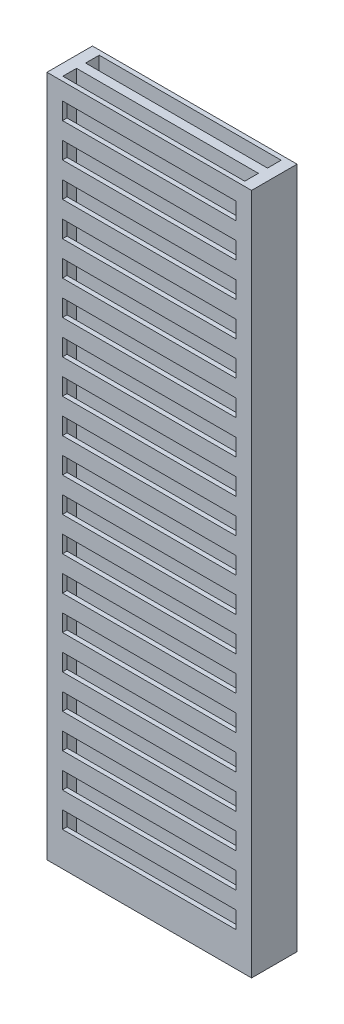
from build123d import *

# Parameters (mm, degrees)
SKETCH1_W                = 9
SKETCH1_H                = 2
BOSS_EXTRUDE1_DEPTH      = 15
CUT_EXTRUDE1_START       = -31
SKETCH2_W                = 8
SKETCH2_H                = 0.6
CUT_EXTRUDE1_DEPTH       = 32
SKETCH3_W                = 7.634272068
SKETCH3_H                = 0.75
CUT_EXTRUDE2_DEPTH       = 0.2
LPATTERN1_COUNT          = 19
LPATTERN1_PITCH          = 1.5
MIRROR2_COPY_1_SKETCH_W  = 7.634272068
MIRROR2_COPY_1_SKETCH_H  = 0.75
MIRROR2_COPY_1_DEPTH     = 0.2
MIRROR2_COPY_2_SKETCH_W  = 7.634272068
MIRROR2_COPY_2_SKETCH_H  = 0.75
MIRROR2_COPY_2_DEPTH     = 0.2
MIRROR2_COPY_3_SKETCH_W  = 7.634272068
MIRROR2_COPY_3_SKETCH_H  = 0.75
MIRROR2_COPY_3_DEPTH     = 0.2
MIRROR2_COPY_4_SKETCH_W  = 7.634272068
MIRROR2_COPY_4_SKETCH_H  = 0.75
MIRROR2_COPY_4_DEPTH     = 0.2
MIRROR2_COPY_5_SKETCH_W  = 7.634272068
MIRROR2_COPY_5_SKETCH_H  = 0.75
MIRROR2_COPY_5_DEPTH     = 0.2
MIRROR2_COPY_6_SKETCH_W  = 7.634272068
MIRROR2_COPY_6_SKETCH_H  = 0.75
MIRROR2_COPY_6_DEPTH     = 0.2
MIRROR2_COPY_7_SKETCH_W  = 7.634272068
MIRROR2_COPY_7_SKETCH_H  = 0.75
MIRROR2_COPY_7_DEPTH     = 0.2
MIRROR2_COPY_8_SKETCH_W  = 7.634272068
MIRROR2_COPY_8_SKETCH_H  = 0.75
MIRROR2_COPY_8_DEPTH     = 0.2
MIRROR2_COPY_9_SKETCH_W  = 7.634272068
MIRROR2_COPY_9_SKETCH_H  = 0.75
MIRROR2_COPY_9_DEPTH     = 0.2
MIRROR2_COPY_10_SKETCH_W = 7.634272068
MIRROR2_COPY_10_SKETCH_H = 0.75
MIRROR2_COPY_10_DEPTH    = 0.2
MIRROR2_COPY_11_SKETCH_W = 7.634272068
MIRROR2_COPY_11_SKETCH_H = 0.75
MIRROR2_COPY_11_DEPTH    = 0.2
MIRROR2_COPY_12_SKETCH_W = 7.634272068
MIRROR2_COPY_12_SKETCH_H = 0.75
MIRROR2_COPY_12_DEPTH    = 0.2
MIRROR2_COPY_13_SKETCH_W = 7.634272068
MIRROR2_COPY_13_SKETCH_H = 0.75
MIRROR2_COPY_13_DEPTH    = 0.2
MIRROR2_COPY_14_SKETCH_W = 7.634272068
MIRROR2_COPY_14_SKETCH_H = 0.75
MIRROR2_COPY_14_DEPTH    = 0.2
MIRROR2_COPY_15_SKETCH_W = 7.634272068
MIRROR2_COPY_15_SKETCH_H = 0.75
MIRROR2_COPY_15_DEPTH    = 0.2
MIRROR2_COPY_16_SKETCH_W = 7.634272068
MIRROR2_COPY_16_SKETCH_H = 0.75
MIRROR2_COPY_16_DEPTH    = 0.2
MIRROR2_COPY_17_SKETCH_W = 7.634272068
MIRROR2_COPY_17_SKETCH_H = 0.75
MIRROR2_COPY_17_DEPTH    = 0.2
MIRROR2_COPY_18_SKETCH_W = 7.634272068
MIRROR2_COPY_18_SKETCH_H = 0.75
MIRROR2_COPY_18_DEPTH    = 0.2


with BuildPart() as part:
    # Sketch1 → Boss-Extrude1 (new body, symmetric)
    with BuildSketch(Plane(origin=(0, 0, 0), x_dir=(1, 0, 0), z_dir=(0, 1, 0))):
        Rectangle(SKETCH1_W, SKETCH1_H)
    extrude(amount=BOSS_EXTRUDE1_DEPTH, both=True)

    # Sketch2 → Cut-Extrude1 (cut)
    with BuildSketch(Plane(origin=(0, 15, 0), x_dir=(1, 0, 0), z_dir=(0, 1, 0)).offset(CUT_EXTRUDE1_START)):
        with Locations((0, 0.5)):
            Rectangle(SKETCH2_W, SKETCH2_H)
    cut_extrude1 = extrude(amount=CUT_EXTRUDE1_DEPTH, mode=Mode.SUBTRACT)

    # Mirror1: Cut-Extrude1 across plane
    add(cut_extrude1.mirror(Plane.XY), mode=Mode.SUBTRACT)

    # Sketch3 → Cut-Extrude2 (cut)
    with BuildSketch(Plane.XY.offset(1)):
        with Locations((0, 13.875)):
            Rectangle(SKETCH3_W, SKETCH3_H)
    cut_extrude2 = extrude(amount=-CUT_EXTRUDE2_DEPTH, mode=Mode.SUBTRACT)

    # LPattern1: Cut-Extrude2 ×19
    with Locations(*[(0, -i * LPATTERN1_PITCH, 0) for i in range(1, LPATTERN1_COUNT)]):
        add(cut_extrude2, mode=Mode.SUBTRACT)

    # Mirror2: Cut-Extrude2 across plane
    add(cut_extrude2.mirror(Plane.XY), mode=Mode.SUBTRACT)

    # Mirror2 copy 1 sketch → Mirror2 copy 1 (cut)
    with BuildSketch(Plane(origin=(0, -1.5, -1), x_dir=(1, 0, 0), z_dir=(0, 0, -1))):
        with Locations((0, -13.875)):
            Rectangle(MIRROR2_COPY_1_SKETCH_W, MIRROR2_COPY_1_SKETCH_H)
    extrude(amount=-MIRROR2_COPY_1_DEPTH, mode=Mode.SUBTRACT)

    # Mirror2 copy 2 sketch → Mirror2 copy 2 (cut)
    with BuildSketch(Plane(origin=(0, -3, -1), x_dir=(1, 0, 0), z_dir=(0, 0, -1))):
        with Locations((0, -13.875)):
            Rectangle(MIRROR2_COPY_2_SKETCH_W, MIRROR2_COPY_2_SKETCH_H)
    extrude(amount=-MIRROR2_COPY_2_DEPTH, mode=Mode.SUBTRACT)

    # Mirror2 copy 3 sketch → Mirror2 copy 3 (cut)
    with BuildSketch(Plane(origin=(0, -4.5, -1), x_dir=(1, 0, 0), z_dir=(0, 0, -1))):
        with Locations((0, -13.875)):
            Rectangle(MIRROR2_COPY_3_SKETCH_W, MIRROR2_COPY_3_SKETCH_H)
    extrude(amount=-MIRROR2_COPY_3_DEPTH, mode=Mode.SUBTRACT)

    # Mirror2 copy 4 sketch → Mirror2 copy 4 (cut)
    with BuildSketch(Plane(origin=(0, -6, -1), x_dir=(1, 0, 0), z_dir=(0, 0, -1))):
        with Locations((0, -13.875)):
            Rectangle(MIRROR2_COPY_4_SKETCH_W, MIRROR2_COPY_4_SKETCH_H)
    extrude(amount=-MIRROR2_COPY_4_DEPTH, mode=Mode.SUBTRACT)

    # Mirror2 copy 5 sketch → Mirror2 copy 5 (cut)
    with BuildSketch(Plane(origin=(0, -7.5, -1), x_dir=(1, 0, 0), z_dir=(0, 0, -1))):
        with Locations((0, -13.875)):
            Rectangle(MIRROR2_COPY_5_SKETCH_W, MIRROR2_COPY_5_SKETCH_H)
    extrude(amount=-MIRROR2_COPY_5_DEPTH, mode=Mode.SUBTRACT)

    # Mirror2 copy 6 sketch → Mirror2 copy 6 (cut)
    with BuildSketch(Plane(origin=(0, -9, -1), x_dir=(1, 0, 0), z_dir=(0, 0, -1))):
        with Locations((0, -13.875)):
            Rectangle(MIRROR2_COPY_6_SKETCH_W, MIRROR2_COPY_6_SKETCH_H)
    extrude(amount=-MIRROR2_COPY_6_DEPTH, mode=Mode.SUBTRACT)

    # Mirror2 copy 7 sketch → Mirror2 copy 7 (cut)
    with BuildSketch(Plane(origin=(0, -10.5, -1), x_dir=(1, 0, 0), z_dir=(0, 0, -1))):
        with Locations((0, -13.875)):
            Rectangle(MIRROR2_COPY_7_SKETCH_W, MIRROR2_COPY_7_SKETCH_H)
    extrude(amount=-MIRROR2_COPY_7_DEPTH, mode=Mode.SUBTRACT)

    # Mirror2 copy 8 sketch → Mirror2 copy 8 (cut)
    with BuildSketch(Plane(origin=(0, -12, -1), x_dir=(1, 0, 0), z_dir=(0, 0, -1))):
        with Locations((0, -13.875)):
            Rectangle(MIRROR2_COPY_8_SKETCH_W, MIRROR2_COPY_8_SKETCH_H)
    extrude(amount=-MIRROR2_COPY_8_DEPTH, mode=Mode.SUBTRACT)

    # Mirror2 copy 9 sketch → Mirror2 copy 9 (cut)
    with BuildSketch(Plane(origin=(0, -13.5, -1), x_dir=(1, 0, 0), z_dir=(0, 0, -1))):
        with Locations((0, -13.875)):
            Rectangle(MIRROR2_COPY_9_SKETCH_W, MIRROR2_COPY_9_SKETCH_H)
    extrude(amount=-MIRROR2_COPY_9_DEPTH, mode=Mode.SUBTRACT)

    # Mirror2 copy 10 sketch → Mirror2 copy 10 (cut)
    with BuildSketch(Plane(origin=(0, -15, -1), x_dir=(1, 0, 0), z_dir=(0, 0, -1))):
        with Locations((0, -13.875)):
            Rectangle(MIRROR2_COPY_10_SKETCH_W, MIRROR2_COPY_10_SKETCH_H)
    extrude(amount=-MIRROR2_COPY_10_DEPTH, mode=Mode.SUBTRACT)

    # Mirror2 copy 11 sketch → Mirror2 copy 11 (cut)
    with BuildSketch(Plane(origin=(0, -16.5, -1), x_dir=(1, 0, 0), z_dir=(0, 0, -1))):
        with Locations((0, -13.875)):
            Rectangle(MIRROR2_COPY_11_SKETCH_W, MIRROR2_COPY_11_SKETCH_H)
    extrude(amount=-MIRROR2_COPY_11_DEPTH, mode=Mode.SUBTRACT)

    # Mirror2 copy 12 sketch → Mirror2 copy 12 (cut)
    with BuildSketch(Plane(origin=(0, -18, -1), x_dir=(1, 0, 0), z_dir=(0, 0, -1))):
        with Locations((0, -13.875)):
            Rectangle(MIRROR2_COPY_12_SKETCH_W, MIRROR2_COPY_12_SKETCH_H)
    extrude(amount=-MIRROR2_COPY_12_DEPTH, mode=Mode.SUBTRACT)

    # Mirror2 copy 13 sketch → Mirror2 copy 13 (cut)
    with BuildSketch(Plane(origin=(0, -19.5, -1), x_dir=(1, 0, 0), z_dir=(0, 0, -1))):
        with Locations((0, -13.875)):
            Rectangle(MIRROR2_COPY_13_SKETCH_W, MIRROR2_COPY_13_SKETCH_H)
    extrude(amount=-MIRROR2_COPY_13_DEPTH, mode=Mode.SUBTRACT)

    # Mirror2 copy 14 sketch → Mirror2 copy 14 (cut)
    with BuildSketch(Plane(origin=(0, -21, -1), x_dir=(1, 0, 0), z_dir=(0, 0, -1))):
        with Locations((0, -13.875)):
            Rectangle(MIRROR2_COPY_14_SKETCH_W, MIRROR2_COPY_14_SKETCH_H)
    extrude(amount=-MIRROR2_COPY_14_DEPTH, mode=Mode.SUBTRACT)

    # Mirror2 copy 15 sketch → Mirror2 copy 15 (cut)
    with BuildSketch(Plane(origin=(0, -22.5, -1), x_dir=(1, 0, 0), z_dir=(0, 0, -1))):
        with Locations((0, -13.875)):
            Rectangle(MIRROR2_COPY_15_SKETCH_W, MIRROR2_COPY_15_SKETCH_H)
    extrude(amount=-MIRROR2_COPY_15_DEPTH, mode=Mode.SUBTRACT)

    # Mirror2 copy 16 sketch → Mirror2 copy 16 (cut)
    with BuildSketch(Plane(origin=(0, -24, -1), x_dir=(1, 0, 0), z_dir=(0, 0, -1))):
        with Locations((0, -13.875)):
            Rectangle(MIRROR2_COPY_16_SKETCH_W, MIRROR2_COPY_16_SKETCH_H)
    extrude(amount=-MIRROR2_COPY_16_DEPTH, mode=Mode.SUBTRACT)

    # Mirror2 copy 17 sketch → Mirror2 copy 17 (cut)
    with BuildSketch(Plane(origin=(0, -25.5, -1), x_dir=(1, 0, 0), z_dir=(0, 0, -1))):
        with Locations((0, -13.875)):
            Rectangle(MIRROR2_COPY_17_SKETCH_W, MIRROR2_COPY_17_SKETCH_H)
    extrude(amount=-MIRROR2_COPY_17_DEPTH, mode=Mode.SUBTRACT)

    # Mirror2 copy 18 sketch → Mirror2 copy 18 (cut)
    with BuildSketch(Plane(origin=(0, -27, -1), x_dir=(1, 0, 0), z_dir=(0, 0, -1))):
        with Locations((0, -13.875)):
            Rectangle(MIRROR2_COPY_18_SKETCH_W, MIRROR2_COPY_18_SKETCH_H)
    extrude(amount=-MIRROR2_COPY_18_DEPTH, mode=Mode.SUBTRACT)


solid = part.part
